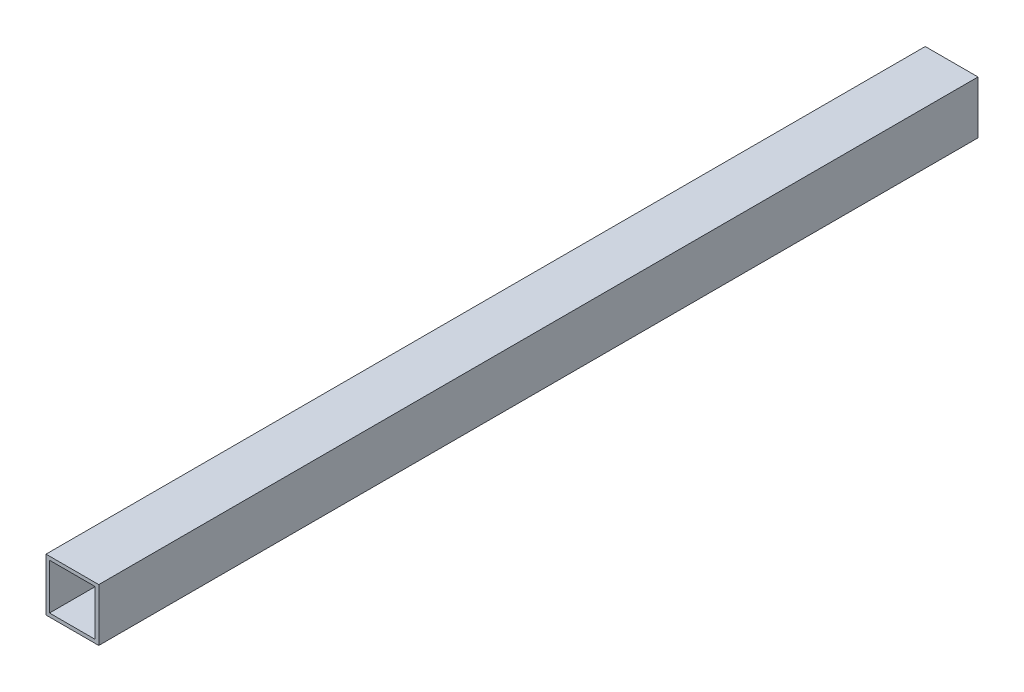
from build123d import *

# Parameters (mm, degrees)
SKETCH3_W           = 15
SKETCH3_H           = 15
SKETCH3_W_2         = 13
SKETCH3_H_2         = 13
EXTRUDE_THIN1_DEPTH = 250


with BuildPart() as part:
    # Sketch3 → Extrude-Thin1 (new body)
    with BuildSketch(Plane.XY):
        with Locations((7.5, 7.5)):
            Rectangle(SKETCH3_W, SKETCH3_H)
        with Locations((7.5, 7.5)):
            Rectangle(SKETCH3_W_2, SKETCH3_H_2, mode=Mode.SUBTRACT)
    extrude(amount=EXTRUDE_THIN1_DEPTH)


solid = part.part
